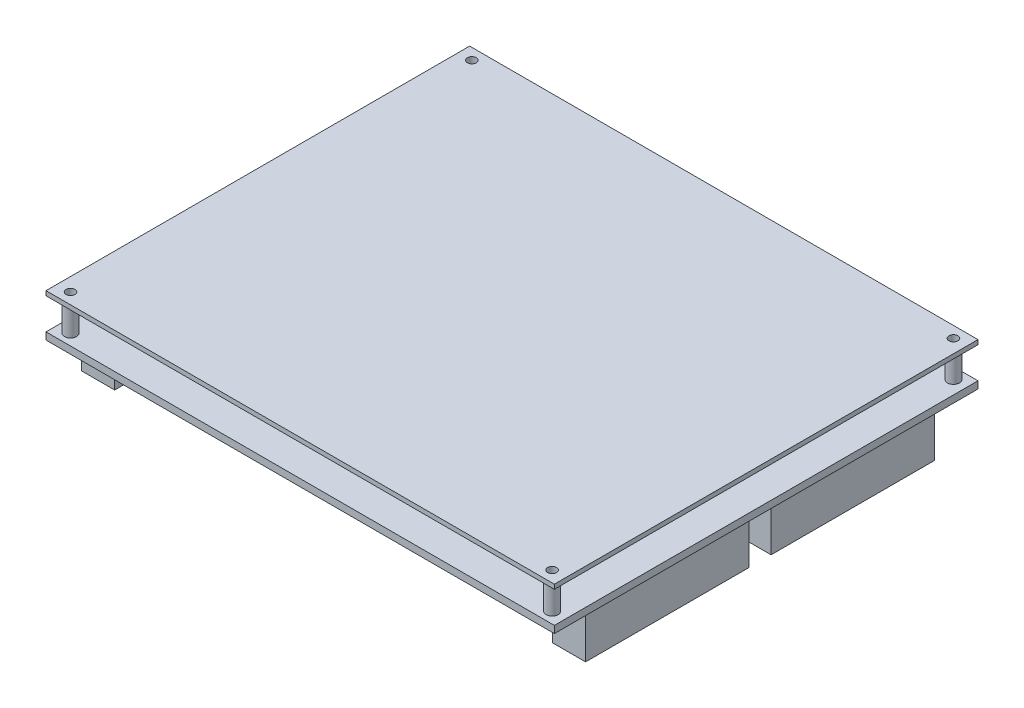
from build123d import *

# Parameters (mm, degrees)
SKETCH3_W          = 114
SKETCH3_H          = 95
EXTRUDE1_DEPTH     = 1.6
SKETCH4_W          = 7.4
SKETCH4_H          = 36.6
EXTRUDE2_DEPTH     = 9.5
SKETCH5_R          = 1.35
EXTRUDE3_DEPTH     = 7
SKETCH7_W          = 114
SKETCH7_H          = 95
EXTRUDE4_DEPTH     = 1
SKETCH8_R          = 1
CUT_EXTRUDE1_DEPTH = 20.1


with BuildPart() as part:
    # Sketch3 → Extrude1 (new body)
    with BuildSketch(Plane(origin=(0, 0, 0), x_dir=(1, 0, 0), z_dir=(0, 1, 0))):
        Rectangle(SKETCH3_W, SKETCH3_H)
    extrude(amount=EXTRUDE1_DEPTH)

    # Sketch4 → Extrude2 (add)
    with BuildSketch(Plane.XZ):
        with Locations((-52.8, 21.7)):
            Rectangle(SKETCH4_W, SKETCH4_H)
        with Locations((-52.8, -24.1)):
            Rectangle(SKETCH4_W, SKETCH4_H)
        with Locations((52.8, 21.7)):
            Rectangle(SKETCH4_W, SKETCH4_H)
        with Locations((52.8, -19.9)):
            Rectangle(SKETCH4_W, SKETCH4_H)
    extrude(amount=EXTRUDE2_DEPTH)

    # Sketch5 → Extrude3 (add)
    with BuildSketch(Plane(origin=(0, 1.6, 0), x_dir=(-1, 0, 0), z_dir=(0, 1, 0))):
        with Locations((54, -45)):
            Circle(SKETCH5_R)
        with Locations((54, 45)):
            Circle(SKETCH5_R)
        with Locations((-54, 45)):
            Circle(SKETCH5_R)
        with Locations((-54, -45)):
            Circle(SKETCH5_R)
    extrude(amount=EXTRUDE3_DEPTH)

    # Sketch7 → Extrude4 (add)
    with BuildSketch(Plane(origin=(0, 8.6, 0), x_dir=(-1, 0, 0), z_dir=(0, 1, 0))):
        Rectangle(SKETCH7_W, SKETCH7_H)
    extrude(amount=EXTRUDE4_DEPTH)

    # Sketch8 → Cut-Extrude1 (cut, through all)
    with BuildSketch(Plane(origin=(0, 9.6, 0), x_dir=(-1, 0, 0), z_dir=(0, 1, 0))):
        with Locations((54, -45)):
            Circle(SKETCH8_R)
        with Locations((54, 45)):
            Circle(SKETCH8_R)
        with Locations((-54, 45)):
            Circle(SKETCH8_R)
        with Locations((-54, -45)):
            Circle(SKETCH8_R)
    extrude(amount=-CUT_EXTRUDE1_DEPTH, mode=Mode.SUBTRACT)


solid = part.part
